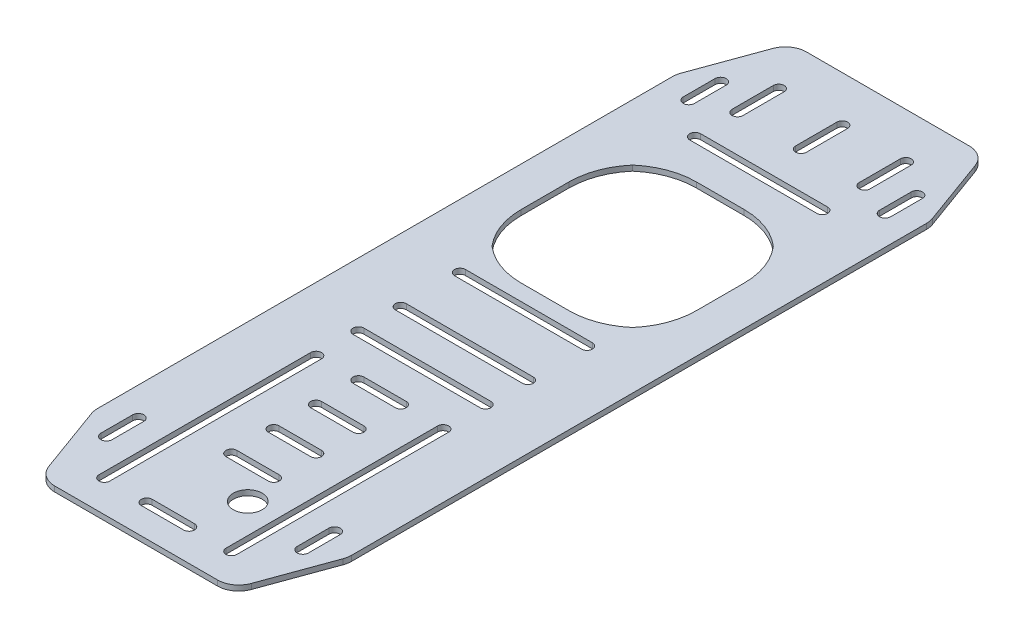
from build123d import *

# Parameters (mm, degrees)
SKETCH1_W           = 152.4
SKETCH1_H           = 660.4
BOSS_EXTRUDE1_DEPTH = 3.18
CUT_EXTRUDE2_DEPTH  = 4.18
CUT_EXTRUDE3_DEPTH  = 4.18
CUT_EXTRUDE4_DEPTH  = 4.18
FILLET1_R           = 12.7
CUT_EXTRUDE6_REACH  = 5.18
SKETCH7_W           = 152.4
SKETCH7_H           = 209.55
CUT_EXTRUDE7_REACH  = 5.18
FILLET2_R           = 12.7
CUT_EXTRUDE8_REACH  = 5.18
SKETCH6_R           = 8.636
CUT_EXTRUDE9_DEPTH  = 4.18
CUT_EXTRUDE10_DEPTH = 4.18


with BuildPart() as part:
    # Sketch1 → Boss-Extrude1 (new body)
    with BuildSketch(Plane(origin=(0, 0, 0), x_dir=(1, 0, 0), z_dir=(0, 1, 0))):
        Rectangle(SKETCH1_W, SKETCH1_H)
    extrude(amount=BOSS_EXTRUDE1_DEPTH)

    # Sketch3 → Cut-Extrude2 (cut, through all)
    with BuildSketch(Plane(origin=(0, 3.18, 0), x_dir=(1, 0, 0), z_dir=(0, 1, 0))):
        with BuildLine():
            Line((-38.1, 54.0639), (38.1, 54.0639))
            ThreePointArc((38.1, 54.0639), (41.3639, 50.8), (38.1, 47.5361))
            Line((38.1, 47.5361), (-38.1, 47.5361))
            ThreePointArc((-38.1, 47.5361), (-41.3639, 50.8), (-38.1, 54.0639))
        make_face()
        with BuildLine():
            Line((-41.3639, 25.4), (-41.3639, -101.6))
            ThreePointArc((-41.3639, -101.6), (-38.1, -104.8639), (-34.8361, -101.6))
            Line((-34.8361, -101.6), (-34.8361, 25.4))
            ThreePointArc((-34.8361, 25.4), (-38.1, 28.6639), (-41.3639, 25.4))
        make_face()
        with BuildLine():
            Line((41.3639, 25.4), (41.3639, -101.6))
            ThreePointArc((41.3639, -101.6), (38.1, -104.8639), (34.8361, -101.6))
            Line((34.8361, -101.6), (34.8361, 25.4))
            ThreePointArc((34.8361, 25.4), (38.1, 28.6639), (41.3639, 25.4))
        make_face()
        with BuildLine():
            Line((-38.1, -130.2639), (38.1, -130.2639))
            ThreePointArc((38.1, -130.2639), (41.3639, -127), (38.1, -123.7361))
            Line((38.1, -123.7361), (-38.1, -123.7361))
            ThreePointArc((-38.1, -123.7361), (-41.3639, -127), (-38.1, -130.2639))
        make_face()
        with BuildLine():
            Line((41.3639, -279.4), (41.3639, -152.4))
            ThreePointArc((41.3639, -152.4), (38.1, -149.1361), (34.8361, -152.4))
            Line((34.8361, -152.4), (34.8361, -279.4))
            ThreePointArc((34.8361, -279.4), (38.1, -282.6639), (41.3639, -279.4))
        make_face()
        with BuildLine():
            Line((-41.3639, -279.4), (-41.3639, -152.4))
            ThreePointArc((-41.3639, -152.4), (-38.1, -149.1361), (-34.8361, -152.4))
            Line((-34.8361, -152.4), (-34.8361, -279.4))
            ThreePointArc((-34.8361, -279.4), (-38.1, -282.6639), (-41.3639, -279.4))
        make_face()
        with BuildLine():
            Line((-38.1, -301.5361), (38.1, -301.5361))
            ThreePointArc((38.1, -301.5361), (41.3639, -304.8), (38.1, -308.0639))
            Line((38.1, -308.0639), (-38.1, -308.0639))
            ThreePointArc((-38.1, -308.0639), (-41.3639, -304.8), (-38.1, -301.5361))
        make_face()
        with BuildLine():
            Line((-12.7, -276.1361), (12.7, -276.1361))
            ThreePointArc((12.7, -276.1361), (15.9639, -279.4), (12.7, -282.6639))
            Line((12.7, -282.6639), (-12.7, -282.6639))
            ThreePointArc((-12.7, -282.6639), (-15.9639, -279.4), (-12.7, -276.1361))
        make_face()
        with BuildLine():
            Line((-12.7, -225.3361), (12.7, -225.3361))
            ThreePointArc((12.7, -225.3361), (15.9639, -228.6), (12.7, -231.8639))
            Line((12.7, -231.8639), (-12.7, -231.8639))
            ThreePointArc((-12.7, -231.8639), (-15.9639, -228.6), (-12.7, -225.3361))
        make_face()
        with BuildLine():
            Line((-12.7, -199.9361), (12.7, -199.9361))
            ThreePointArc((12.7, -199.9361), (15.9639, -203.2), (12.7, -206.4639))
            Line((12.7, -206.4639), (-12.7, -206.4639))
            ThreePointArc((-12.7, -206.4639), (-15.9639, -203.2), (-12.7, -199.9361))
        make_face()
        with BuildLine():
            Line((-12.7, -174.5361), (12.7, -174.5361))
            ThreePointArc((12.7, -174.5361), (15.9639, -177.8), (12.7, -181.0639))
            Line((12.7, -181.0639), (-12.7, -181.0639))
            ThreePointArc((-12.7, -181.0639), (-15.9639, -177.8), (-12.7, -174.5361))
        make_face()
        with BuildLine():
            Line((-12.7, -149.1361), (12.7, -149.1361))
            ThreePointArc((12.7, -149.1361), (15.9639, -152.4), (12.7, -155.6639))
            Line((12.7, -155.6639), (-12.7, -155.6639))
            ThreePointArc((-12.7, -155.6639), (-15.9639, -152.4), (-12.7, -149.1361))
        make_face()
        with BuildLine():
            Line((-12.7, 22.1361), (12.7, 22.1361))
            ThreePointArc((12.7, 22.1361), (15.9639, 25.4), (12.7, 28.6639))
            Line((12.7, 28.6639), (-12.7, 28.6639))
            ThreePointArc((-12.7, 28.6639), (-15.9639, 25.4), (-12.7, 22.1361))
        make_face()
        with BuildLine():
            Line((-12.7, -3.2639), (12.7, -3.2639))
            ThreePointArc((12.7, -3.2639), (15.9639, 0), (12.7, 3.2639))
            Line((12.7, 3.2639), (-12.7, 3.2639))
            ThreePointArc((-12.7, 3.2639), (-15.9639, 0), (-12.7, -3.2639))
        make_face()
        with BuildLine():
            Line((-12.7, -28.6639), (12.7, -28.6639))
            ThreePointArc((12.7, -28.6639), (15.9639, -25.4), (12.7, -22.1361))
            Line((12.7, -22.1361), (-12.7, -22.1361))
            ThreePointArc((-12.7, -22.1361), (-15.9639, -25.4), (-12.7, -28.6639))
        make_face()
        with BuildLine():
            Line((-12.7, -54.0639), (12.7, -54.0639))
            ThreePointArc((12.7, -54.0639), (15.9639, -50.8), (12.7, -47.5361))
            Line((12.7, -47.5361), (-12.7, -47.5361))
            ThreePointArc((-12.7, -47.5361), (-15.9639, -50.8), (-12.7, -54.0639))
        make_face()
        with BuildLine():
            Line((-12.7, -104.8639), (12.7, -104.8639))
            ThreePointArc((12.7, -104.8639), (15.9639, -101.6), (12.7, -98.3361))
            Line((12.7, -98.3361), (-12.7, -98.3361))
            ThreePointArc((-12.7, -98.3361), (-15.9639, -101.6), (-12.7, -104.8639))
        make_face()
        with BuildLine():
            Line((-38.1, 72.9361), (38.1, 72.9361))
            ThreePointArc((38.1, 72.9361), (41.3639, 76.2), (38.1, 79.4639))
            Line((38.1, 79.4639), (-38.1, 79.4639))
            ThreePointArc((-38.1, 79.4639), (-41.3639, 76.2), (-38.1, 72.9361))
        make_face()
        with BuildLine():
            Line((-38.1, 249.471688), (38.1, 249.471688))
            ThreePointArc((38.1, 249.471688), (41.3639, 252.735588), (38.1, 255.999488))
            Line((38.1, 255.999488), (-38.1, 255.999488))
            ThreePointArc((-38.1, 255.999488), (-41.3639, 252.735588), (-38.1, 249.471688))
        make_face()
        with BuildLine():
            Line((-34.8361, 302.83925906), (-34.8361, 278.135588))
            ThreePointArc((-34.8361, 278.135588), (-38.1, 274.871688), (-41.3639, 278.135588))
            Line((-41.3639, 278.135588), (-41.3639, 302.83925906))
            ThreePointArc((-41.3639, 302.83925906), (-38.1, 306.10315906), (-34.8361, 302.83925906))
        make_face()
        with BuildLine():
            Line((3.2639, 302.83925906), (3.2639, 278.135588))
            ThreePointArc((3.2639, 278.135588), (0, 274.871688), (-3.2639, 278.135588))
            Line((-3.2639, 278.135588), (-3.2639, 302.83925906))
            ThreePointArc((-3.2639, 302.83925906), (0, 306.10315906), (3.2639, 302.83925906))
        make_face()
        with BuildLine():
            Line((41.3639, 302.83925906), (41.3639, 278.135588))
            ThreePointArc((41.3639, 278.135588), (38.1, 274.871688), (34.8361, 278.135588))
            Line((34.8361, 278.135588), (34.8361, 302.83925906))
            ThreePointArc((34.8361, 302.83925906), (38.1, 306.10315906), (41.3639, 302.83925906))
        make_face()
        with BuildLine():
            Line((-38.1, 203.751688), (38.1, 203.751688))
            ThreePointArc((38.1, 203.751688), (41.3639, 207.015588), (38.1, 210.279488))
            Line((38.1, 210.279488), (-38.1, 210.279488))
            ThreePointArc((-38.1, 210.279488), (-41.3639, 207.015588), (-38.1, 203.751688))
        make_face()
    extrude(amount=-CUT_EXTRUDE2_DEPTH, mode=Mode.SUBTRACT)

    # Sketch4 → Cut-Extrude3 (cut, through all)
    with BuildSketch(Plane(origin=(0, 3.18, 0), x_dir=(1, 0, 0), z_dir=(0, 1, 0))):
        with BuildLine():
            Line((-14.361406616, 124.611310304), (14.361406616, 124.611310304))
            ThreePointArc((14.361406616, 124.611310304), (29.204496188, 127.284854581), (42.181875503, 134.969434801))
            ThreePointArc((42.181875503, 134.969434801), (49.866455724, 147.946814116), (52.54, 162.789903688))
            Line((52.54, 162.789903688), (52.54, 191.512716921))
            ThreePointArc((52.54, 191.512716921), (49.866455724, 206.355806493), (42.181875503, 219.333185808))
            ThreePointArc((42.181875503, 219.333185808), (29.204496188, 227.017766028), (14.361406616, 229.691310304))
            Line((14.361406616, 229.691310304), (-14.361406616, 229.691310304))
            ThreePointArc((-14.361406616, 229.691310304), (-29.204496188, 227.017766028), (-42.181875503, 219.333185808))
            ThreePointArc((-42.181875503, 219.333185808), (-49.866455724, 206.355806493), (-52.54, 191.512716921))
            Line((-52.54, 191.512716921), (-52.54, 162.789903688))
            ThreePointArc((-52.54, 162.789903688), (-49.866455724, 147.946814116), (-42.181875503, 134.969434801))
            ThreePointArc((-42.181875503, 134.969434801), (-29.204496188, 127.284854581), (-14.361406616, 124.611310304))
        make_face()
    extrude(amount=-CUT_EXTRUDE3_DEPTH, mode=Mode.SUBTRACT)

    # Sketch5 → Cut-Extrude4 (cut, through all)
    with BuildSketch(Plane.XZ):
        Polygon((76.2, 279.4), (57.710312099, 330.2), (76.2, 330.2), align=None)
        Polygon((-57.710312099, 330.2), (-76.2, 330.2), (-76.2, 279.4), align=None)
        Polygon((-76.2, -279.4), (-57.710312099, -330.2), (-76.2, -330.2), align=None)
        Polygon((57.710312099, -330.2), (76.2, -330.2), (76.2, -279.4), align=None)
    extrude(amount=-CUT_EXTRUDE4_DEPTH, mode=Mode.SUBTRACT)

    # Fillet1
    fillet1_edges = [part.edges().sort_by_distance(p)[0] for p in [
        (57.710312099, 1.59, -330.2),
        (76.2, 1.59, -279.4),
        (-76.2, 1.59, -279.4),
        (-57.710312099, 1.59, -330.2),
        (-57.710312099, 1.59, 330.2),
        (-76.2, 1.59, 279.4),
        (76.2, 1.59, 279.4),
        (57.710312099, 1.59, 330.2),
    ]]
    fillet(fillet1_edges, radius=FILLET1_R)

    # Sketch7 → Cut-Extrude6 (cut, up to next)
    with BuildSketch(Plane.XZ, mode=Mode.PRIVATE) as cut_extrude6_sk1:
        with Locations((0, 225.425)):
            Rectangle(SKETCH7_W, SKETCH7_H)
    cut_extrude6_tool1 = extrude(cut_extrude6_sk1.sketch, amount=-CUT_EXTRUDE6_REACH, mode=Mode.PRIVATE) & part.part
    add(cut_extrude6_tool1.solids().sort_by_distance((0, 0, 225.425))[0], mode=Mode.SUBTRACT)

    # Sketch8 → Cut-Extrude7 (cut, up to next)
    with BuildSketch(Plane.XZ, mode=Mode.PRIVATE) as cut_extrude7_sk1:
        Polygon((76.2, 69.85), (76.2, 120.65), (57.710312099, 120.65), align=None)
    cut_extrude7_tool1 = extrude(cut_extrude7_sk1.sketch, amount=-CUT_EXTRUDE7_REACH, mode=Mode.PRIVATE) & part.part
    add(cut_extrude7_tool1.solids().sort_by_distance((70.036771, 0, 103.716667))[0], mode=Mode.SUBTRACT)
    # Sketch8 → Cut-Extrude7 (cut, up to next)
    with BuildSketch(Plane.XZ, mode=Mode.PRIVATE) as cut_extrude7_sk2:
        Polygon((-76.2, 120.65), (-57.710312099, 120.65), (-76.2, 69.85), align=None)
    cut_extrude7_tool2 = extrude(cut_extrude7_sk2.sketch, amount=-CUT_EXTRUDE7_REACH, mode=Mode.PRIVATE) & part.part
    add(cut_extrude7_tool2.solids().sort_by_distance((-70.036771, 0, 103.716667))[0], mode=Mode.SUBTRACT)

    # Fillet2
    fillet2_edges = [part.edges().sort_by_distance(p)[0] for p in [
        (76.2, 1.59, 69.85),
        (57.710312099, 1.59, 120.65),
        (-76.2, 1.59, 69.85),
        (-57.710312099, 1.59, 120.65),
    ]]
    fillet(fillet2_edges, radius=FILLET2_R)

    # Sketch9 → Cut-Extrude8 (cut, up to next)
    with BuildSketch(Plane.XZ, mode=Mode.PRIVATE) as cut_extrude8_sk1:
        with BuildLine():
            Line((62.052200001, -269.875), (62.052200001, -288.925))
            ThreePointArc((62.052200001, -288.925), (58.674000001, -292.3032), (55.295800001, -288.925))
            Line((55.295800001, -288.925), (55.295800001, -269.875))
            ThreePointArc((55.295800001, -269.875), (58.674000001, -266.4968), (62.052200001, -269.875))
        make_face()
    cut_extrude8_tool1 = extrude(cut_extrude8_sk1.sketch, amount=-CUT_EXTRUDE8_REACH, mode=Mode.PRIVATE) & part.part
    add(cut_extrude8_tool1.solids().sort_by_distance((58.674, 0, -279.4))[0], mode=Mode.SUBTRACT)
    # Sketch9 → Cut-Extrude8 (cut, up to next)
    with BuildSketch(Plane.XZ, mode=Mode.PRIVATE) as cut_extrude8_sk2:
        with BuildLine():
            Line((-55.657585683, -269.875), (-55.657585683, -288.925))
            ThreePointArc((-55.657585683, -288.925), (-59.035785683, -292.3032), (-62.413985683, -288.925))
            Line((-62.413985683, -288.925), (-62.413985683, -269.875))
            ThreePointArc((-62.413985683, -269.875), (-59.035785683, -266.4968), (-55.657585683, -269.875))
        make_face()
    cut_extrude8_tool2 = extrude(cut_extrude8_sk2.sketch, amount=-CUT_EXTRUDE8_REACH, mode=Mode.PRIVATE) & part.part
    add(cut_extrude8_tool2.solids().sort_by_distance((-59.035786, 0, -279.4))[0], mode=Mode.SUBTRACT)
    # Sketch9 → Cut-Extrude8 (cut, up to next)
    with BuildSketch(Plane.XZ, mode=Mode.PRIVATE) as cut_extrude8_sk3:
        with BuildLine():
            Line((-55.657585683, 60.325), (-55.657585683, 79.375))
            ThreePointArc((-55.657585683, 79.375), (-59.035785683, 82.7532), (-62.413985683, 79.375))
            Line((-62.413985683, 79.375), (-62.413985683, 60.325))
            ThreePointArc((-62.413985683, 60.325), (-59.035785683, 56.9468), (-55.657585683, 60.325))
        make_face()
    cut_extrude8_tool3 = extrude(cut_extrude8_sk3.sketch, amount=-CUT_EXTRUDE8_REACH, mode=Mode.PRIVATE) & part.part
    add(cut_extrude8_tool3.solids().sort_by_distance((-59.035786, 0, 69.85))[0], mode=Mode.SUBTRACT)
    # Sketch9 → Cut-Extrude8 (cut, up to next)
    with BuildSketch(Plane.XZ, mode=Mode.PRIVATE) as cut_extrude8_sk4:
        with BuildLine():
            Line((62.052200001, 60.325), (62.052200001, 79.375))
            ThreePointArc((62.052200001, 79.375), (58.674000001, 82.7532), (55.295800001, 79.375))
            Line((55.295800001, 79.375), (55.295800001, 60.325))
            ThreePointArc((55.295800001, 60.325), (58.674000001, 56.9468), (62.052200001, 60.325))
        make_face()
    cut_extrude8_tool4 = extrude(cut_extrude8_sk4.sketch, amount=-CUT_EXTRUDE8_REACH, mode=Mode.PRIVATE) & part.part
    add(cut_extrude8_tool4.solids().sort_by_distance((58.674, 0, 69.85))[0], mode=Mode.SUBTRACT)

    # Sketch6 → Cut-Extrude9 (cut, through all)
    with BuildSketch(Plane(origin=(0, 3.18, 0), x_dir=(1, 0, 0), z_dir=(0, 1, 0))):
        with Locations((17.106, -70.8034)):
            Circle(SKETCH6_R)
    extrude(amount=-CUT_EXTRUDE9_DEPTH, mode=Mode.SUBTRACT)

    # Sketch10 → Cut-Extrude10 (cut, through all)
    with BuildSketch(Plane.XZ):
        with BuildLine():
            Line((-38.1, -108.431510304), (38.1, -108.431510304))
            ThreePointArc((38.1, -108.431510304), (41.3639, -111.695410304), (38.1, -114.959310304))
            Line((38.1, -114.959310304), (-38.1, -114.959310304))
            ThreePointArc((-38.1, -114.959310304), (-41.3639, -111.695410304), (-38.1, -108.431510304))
        make_face()
    extrude(amount=-CUT_EXTRUDE10_DEPTH, mode=Mode.SUBTRACT)


solid = part.part
